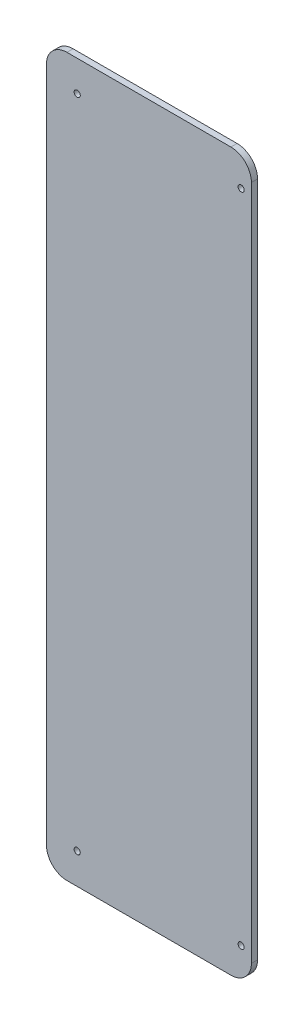
from build123d import *

# Parameters (mm, degrees)
ESQUISSE1_R        = 1.5
BOSS_EXTRU_1_DEPTH = 3


with BuildPart() as part:
    # Esquisse1 → Boss.-Extru.1 (new body)
    with BuildSketch(Plane.XY):
        with BuildLine():
            Line((10, 0), (90, 0))
            ThreePointArc((90, 0), (97.071067812, 2.928932188), (100, 10))
            Line((100, 10), (100, 340))
            ThreePointArc((100, 340), (97.071067812, 347.071067812), (90, 350))
            Line((90, 350), (10, 350))
            ThreePointArc((10, 350), (2.928932188, 347.071067812), (0, 340))
            Line((0, 340), (0, 10))
            ThreePointArc((0, 10), (2.928932188, 2.928932188), (10, 0))
        make_face()
        with Locations((95, 335)):
            Circle(ESQUISSE1_R, mode=Mode.SUBTRACT)
        with Locations((15, 335)):
            Circle(ESQUISSE1_R, mode=Mode.SUBTRACT)
        with Locations((95, 15)):
            Circle(ESQUISSE1_R, mode=Mode.SUBTRACT)
        with Locations((15, 15)):
            Circle(ESQUISSE1_R, mode=Mode.SUBTRACT)
    extrude(amount=BOSS_EXTRU_1_DEPTH)


solid = part.part
